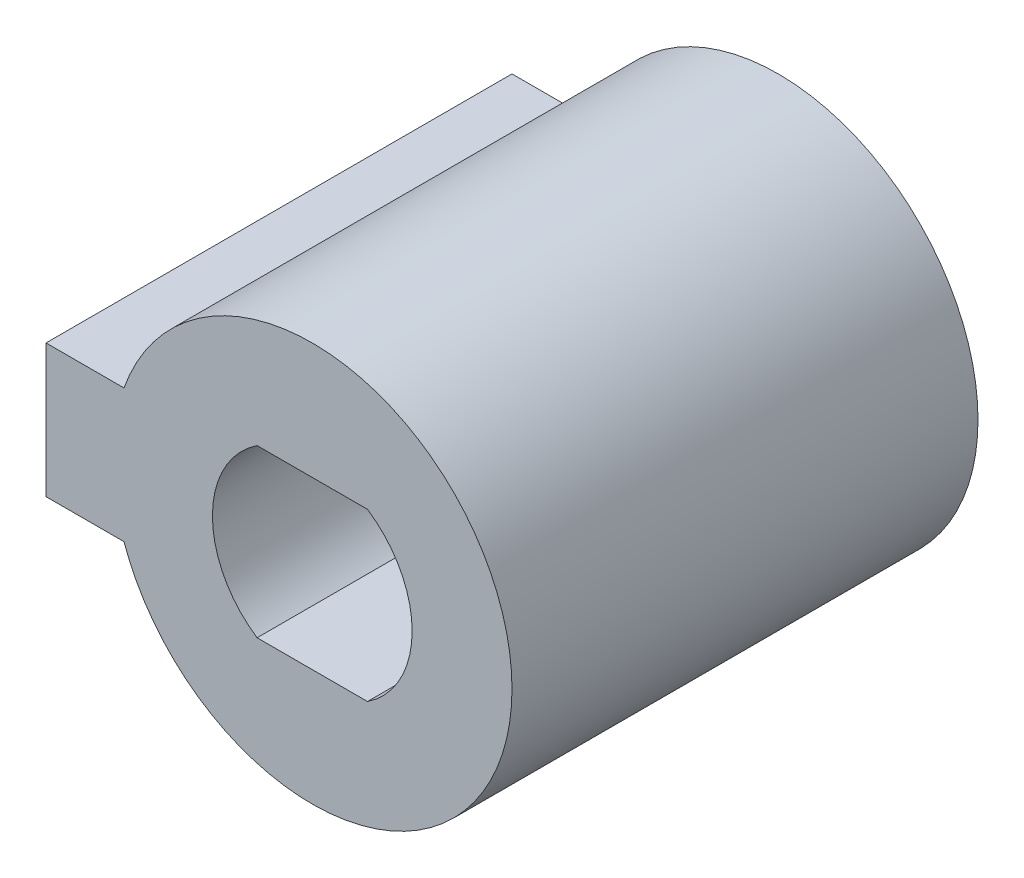
from build123d import *

# Parameters (mm, degrees)
EXTRUDE_1_DEPTH      = 27
EXTRUDE_1_DEPTH_BACK = 1


with BuildPart() as part:
    # Эскиз1 → Бобышка-Вытянуть1 (new body, two sides)
    with BuildSketch(Plane.XY) as extrude_1_sk:
        with BuildLine():
            Line((-11.313708499, 4), (-16, 4))
            Line((-16, 4), (-16, -4))
            Line((-16, -4), (-11.313708499, -4))
            ThreePointArc((-11.313708499, -4), (12, 0), (-11.313708499, 4))
        make_face()
        with BuildLine():
            Line((3.31662479, 5), (-3.31662479, 5))
            ThreePointArc((-3.31662479, 5), (-6, 0), (-3.31662479, -5))
            Line((-3.31662479, -5), (3.31662479, -5))
            ThreePointArc((3.31662479, -5), (6, 0), (3.31662479, 5))
        make_face(mode=Mode.SUBTRACT)
    extrude(amount=EXTRUDE_1_DEPTH)
    extrude(extrude_1_sk.sketch, amount=-EXTRUDE_1_DEPTH_BACK)


solid = part.part
